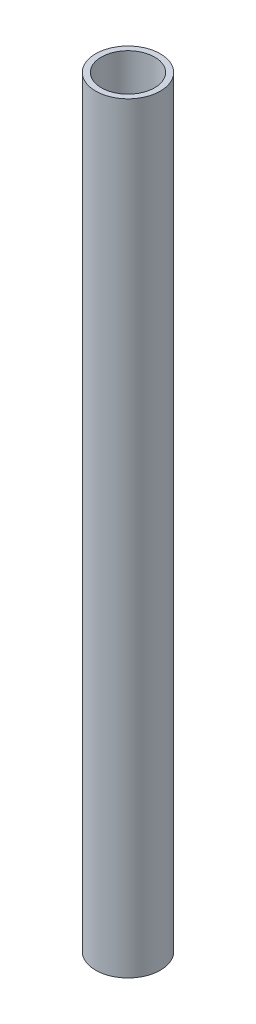
from build123d import *

# Parameters (mm, degrees)
SKETCH_1_R      = 17
SKETCH_1_R_2    = 14
EXTRUDE_1_DEPTH = 400


with BuildPart() as part:
    # Эскиз1 → Вытянуть-Тонкостенный1 (new body)
    with BuildSketch(Plane(origin=(0, 0, 0), x_dir=(1, 0, 0), z_dir=(0, 1, 0))):
        Circle(SKETCH_1_R)
        Circle(SKETCH_1_R_2, mode=Mode.SUBTRACT)
    extrude(amount=EXTRUDE_1_DEPTH)


solid = part.part
